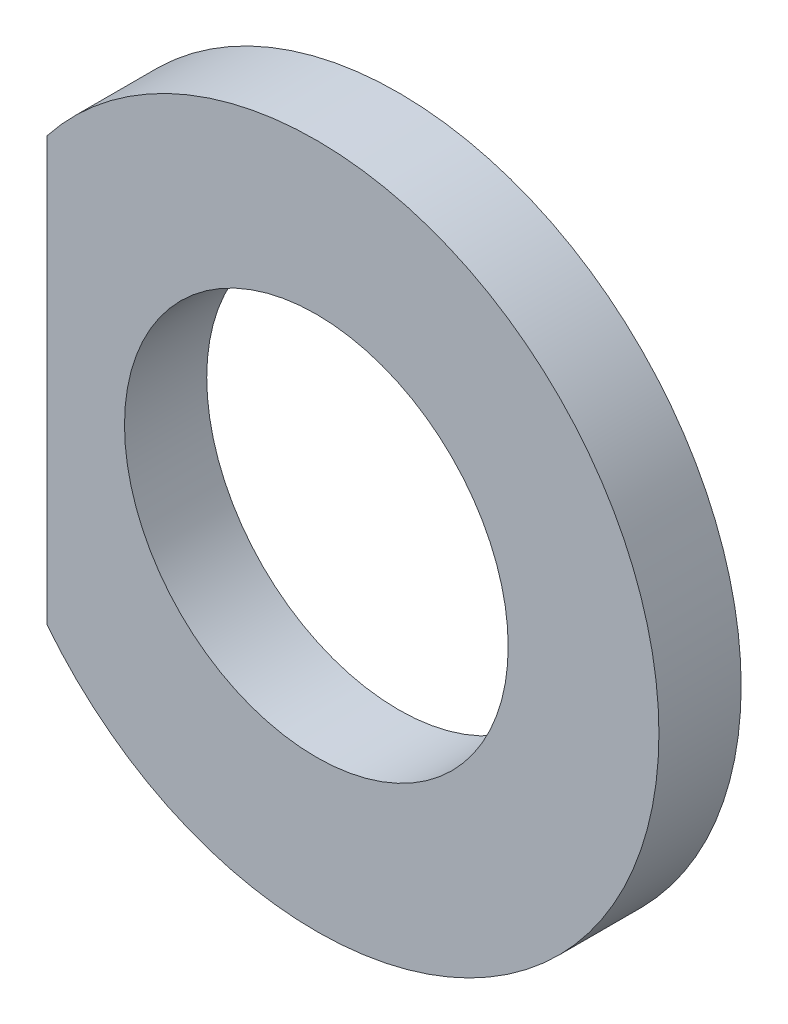
from build123d import *

# Parameters (mm, degrees)
SKETCH1_R      = 4.2
EXTRUDE1_DEPTH = 1.8


with BuildPart() as part:
    # Sketch1 → Extrude1 (new body)
    with BuildSketch(Plane.XY):
        with BuildLine():
            Line((-5.9, 4.630334761), (-5.9, -4.630334761))
            ThreePointArc((-5.9, -4.630334761), (7.5, 0), (-5.9, 4.630334761))
        make_face()
        Circle(SKETCH1_R, mode=Mode.SUBTRACT)
    extrude(amount=-EXTRUDE1_DEPTH)


solid = part.part
